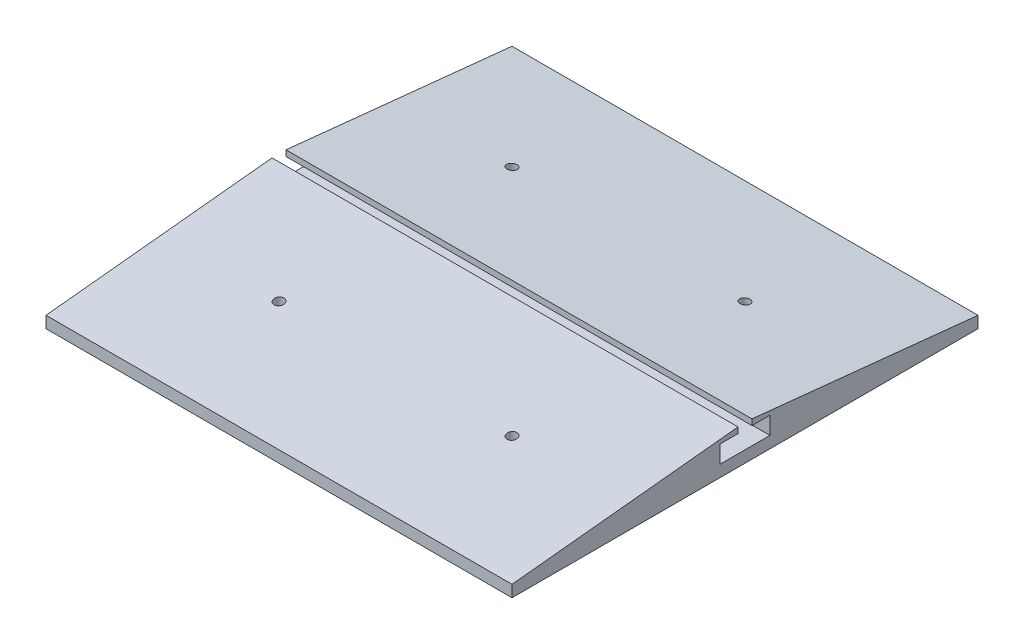
from build123d import *

# Parameters (mm, degrees)
SKETCH1_W           = 200
SKETCH1_H           = 200
BOSS_EXTRUDE1_DEPTH = 5
BOSS_EXTRUDE2_DEPTH = 200
CUT_EXTRUDE9_START  = -200
SKETCH13_W          = 21.4
SKETCH13_H          = 7.5
CUT_EXTRUDE9_DEPTH  = 200
CUT_EXTRUDE14_START = -2
CUT_EXTRUDE14_DEPTH = 3.6
SKETCH17_R          = 2.1
CUT_EXTRUDE15_DEPTH = 16


with BuildPart() as part:
    # Sketch1 → Boss-Extrude1 (new body)
    with BuildSketch(Plane(origin=(0, 0, 0), x_dir=(1, 0, 0), z_dir=(0, 1, 0))):
        Rectangle(SKETCH1_W, SKETCH1_H)
    extrude(amount=BOSS_EXTRUDE1_DEPTH)

    # Sketch9 → Boss-Extrude2 (add)
    with BuildSketch(Plane(origin=(100, 0, 0), x_dir=(0, 0, -1), z_dir=(1, 0, 0))):
        Polygon((-100, 5), (-3, 15), (-3, 5), align=None)
        Polygon((3, 5), (100, 5), (3, 15), align=None)
    extrude(amount=-BOSS_EXTRUDE2_DEPTH)

    # Sketch13 → Cut-Extrude9 (cut)
    with BuildSketch(Plane.ZY.offset(100).offset(CUT_EXTRUDE9_START)):
        with Locations((0, 8.75)):
            Rectangle(SKETCH13_W, SKETCH13_H)
    extrude(amount=CUT_EXTRUDE9_DEPTH, mode=Mode.SUBTRACT)

    # Sketch18 → Cut-Extrude14 (cut)
    with BuildSketch(Plane.XZ.offset(CUT_EXTRUDE14_START)):
        Polygon((-52.136195996, 46.3), (-47.863804004, 46.3), (-45.727608008, 50), (-47.863804004, 53.7), (-52.136195996, 53.7), (-54.272391992, 53.7), (-54.272391992, 46.3), align=None)
        Polygon((47.863804004, 46.3), (52.136195996, 46.3), (54.272391992, 50), (52.136195996, 53.7), (47.863804004, 53.7), (45.727608008, 53.7), (45.727608008, 46.3), align=None)
        Polygon((47.863804004, -53.7), (52.136195996, -53.7), (54.272391992, -50), (52.136195996, -46.3), (47.863804004, -46.3), (45.727608008, -46.3), (45.727608008, -53.7), align=None)
        Polygon((-52.136195996, -53.7), (-47.863804004, -53.7), (-45.727608008, -50), (-47.863804004, -46.3), (-52.136195996, -46.3), (-54.272391992, -46.3), (-54.272391992, -53.7), align=None)
    extrude(amount=-CUT_EXTRUDE14_DEPTH, mode=Mode.SUBTRACT)

    # Sketch17 → Cut-Extrude15 (cut, through all)
    with BuildSketch(Plane.XZ):
        with Locations((-50, 50)):
            Circle(SKETCH17_R)
        with Locations((50, 50)):
            Circle(SKETCH17_R)
        with Locations((50, -50)):
            Circle(SKETCH17_R)
        with Locations((-50, -50)):
            Circle(SKETCH17_R)
    extrude(amount=-CUT_EXTRUDE15_DEPTH, mode=Mode.SUBTRACT)


solid = part.part
